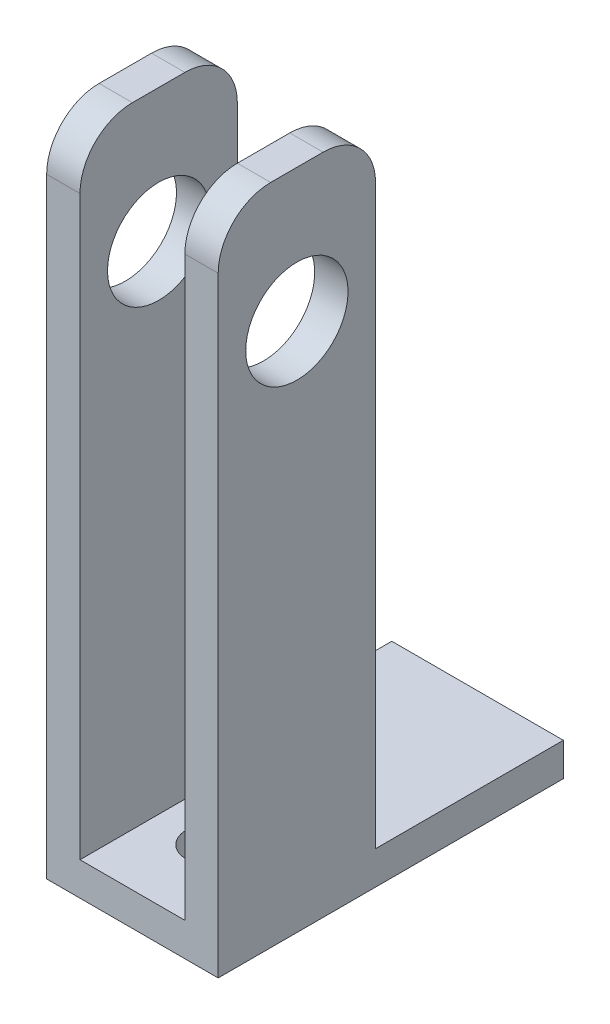
from build123d import *

# Parameters (mm, degrees)
SKETCH1_R                = 10
BOSS_EXTRUDE1_DEPTH      = 6.35
SKETCH5_W                = 20
SKETCH5_H                = 30
BOSS_EXTRUDE2_DEPTH      = 6.35
SKETCH7_W                = 6.35
SKETCH7_H                = 30
BOSS_EXTRUDE3_DEPTH      = 120
BOSS_EXTRUDE3_DEPTH_BACK = 6.35
SKETCH8_R                = 9.75
CUT_EXTRUDE2_DEPTH       = 33.7
SKETCH2_R                = 4.7625
CUT_EXTRUDE1_DEPTH       = 7.35
FILLET2_R                = 10
SKETCH11_W               = 32.7
SKETCH11_H               = 35.8
BOSS_EXTRUDE5_DEPTH      = 6.35


with BuildPart() as part:
    # Sketch1 → Boss-Extrude1 (new body)
    with BuildSketch(Plane(origin=(0, 0, 0), x_dir=(1, 0, 0), z_dir=(0, 1, 0))):
        Circle(SKETCH1_R)
    extrude(amount=BOSS_EXTRUDE1_DEPTH)

    # Sketch5 → Boss-Extrude2 (add)
    with BuildSketch(Plane(origin=(0, 6.35, 0), x_dir=(1, 0, 0), z_dir=(0, 1, 0))):
        Rectangle(SKETCH5_W, SKETCH5_H)
    extrude(amount=-BOSS_EXTRUDE2_DEPTH)

    # Sketch7 → Boss-Extrude3 (add, two sides)
    with BuildSketch(Plane(origin=(0, 6.35, 0), x_dir=(1, 0, 0), z_dir=(0, 1, 0))) as boss_extrude3_sk:
        with Locations((-13.175, 0)):
            Rectangle(SKETCH7_W, SKETCH7_H)
        with Locations((13.175, 0)):
            Rectangle(SKETCH7_W, SKETCH7_H)
    extrude(amount=BOSS_EXTRUDE3_DEPTH)
    extrude(boss_extrude3_sk.sketch, amount=-BOSS_EXTRUDE3_DEPTH_BACK)

    # Sketch8 → Cut-Extrude2 (cut, through all)
    with BuildSketch(Plane.ZY.offset(16.35)):
        with Locations((0, 100.95)):
            Circle(SKETCH8_R)
    extrude(amount=-CUT_EXTRUDE2_DEPTH, mode=Mode.SUBTRACT)

    # Sketch2 → Cut-Extrude1 (cut, through all)
    with BuildSketch(Plane(origin=(0, 6.35, 0), x_dir=(1, 0, 0), z_dir=(0, 1, 0))):
        Circle(SKETCH2_R)
    extrude(amount=-CUT_EXTRUDE1_DEPTH, mode=Mode.SUBTRACT)

    # Fillet2
    fillet2_edges = [part.edges().sort_by_distance(p)[0] for p in [
        (13.175, 126.35, -15),
        (13.175, 126.35, 15),
        (-13.175, 126.35, 15),
        (-13.175, 126.35, -15),
    ]]
    fillet(fillet2_edges, radius=FILLET2_R)

    # Sketch11 → Boss-Extrude5 (add)
    with BuildSketch(Plane.XZ):
        with Locations((0, -32.9)):
            Rectangle(SKETCH11_W, SKETCH11_H)
    extrude(amount=-BOSS_EXTRUDE5_DEPTH)


solid = part.part
